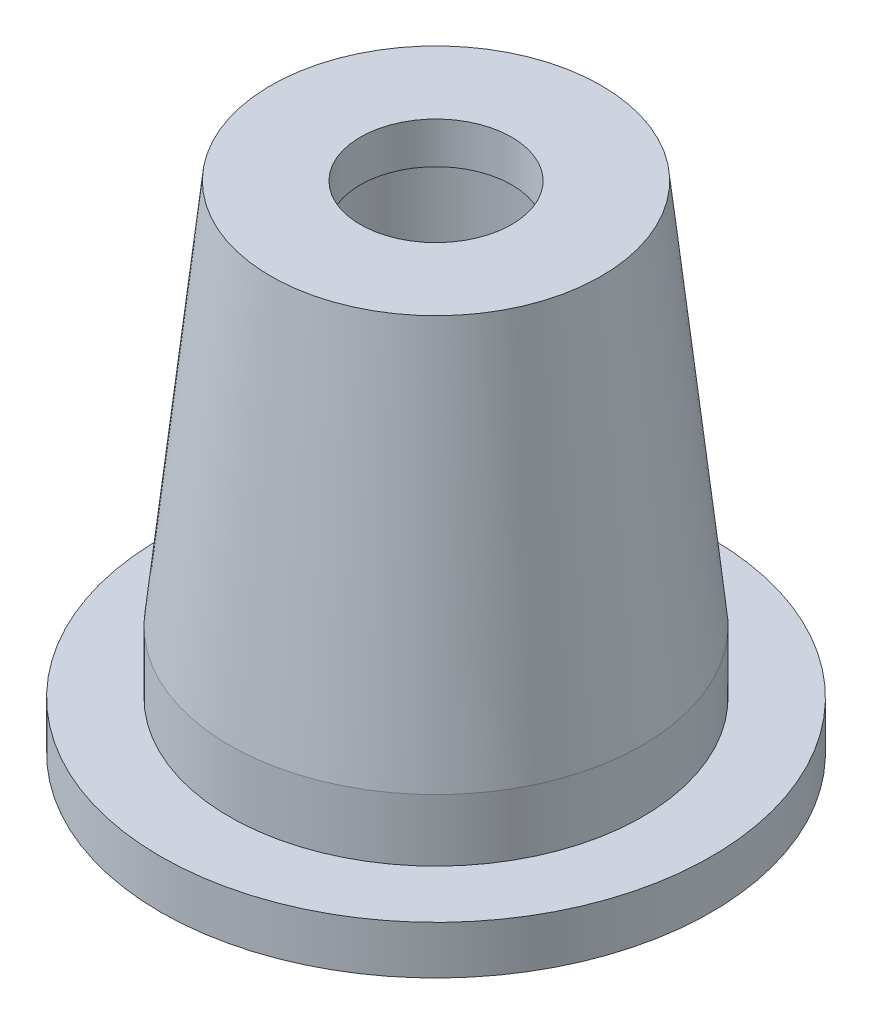
from build123d import *

# Parameters (mm, degrees)
CHAMFER_1_SIZE = 3


with BuildPart() as part:
    # Эскиз1 → Повернуть1 (revolve)
    with BuildSketch(Plane.XY):
        Polygon((9, 0), (20, 0), (20, 3.5), (15, 3.5), (15, 8), (12, 36), (5.5, 36), (5.5, 33), (9, 33), align=None)
    revolve(axis=Axis((0, 0, 0), (0, 1, 0)))

    # Эскиз2 → Вырез-Повернуть1 (revolve, cut)
    with BuildSketch(Plane.XY):
        with BuildLine():
            Line((13.5, -3.5), (13.5, -0.5))
            ThreePointArc((13.5, -0.5), (15.5, 1.5), (17.5, -0.5))
            Line((17.5, -0.5), (17.5, -3.5))
            ThreePointArc((17.5, -3.5), (15.5, -5.5), (13.5, -3.5))
        make_face()
    revolve(axis=Axis((0, 0, 0), (0, 1, 0)), mode=Mode.SUBTRACT)

    # Фаска1
    chamfer_1_edges = [part.edges().sort_by_distance(p)[0] for p in [
        (-9, 0, 0),
    ]]
    chamfer(chamfer_1_edges, length=CHAMFER_1_SIZE)


solid = part.part
